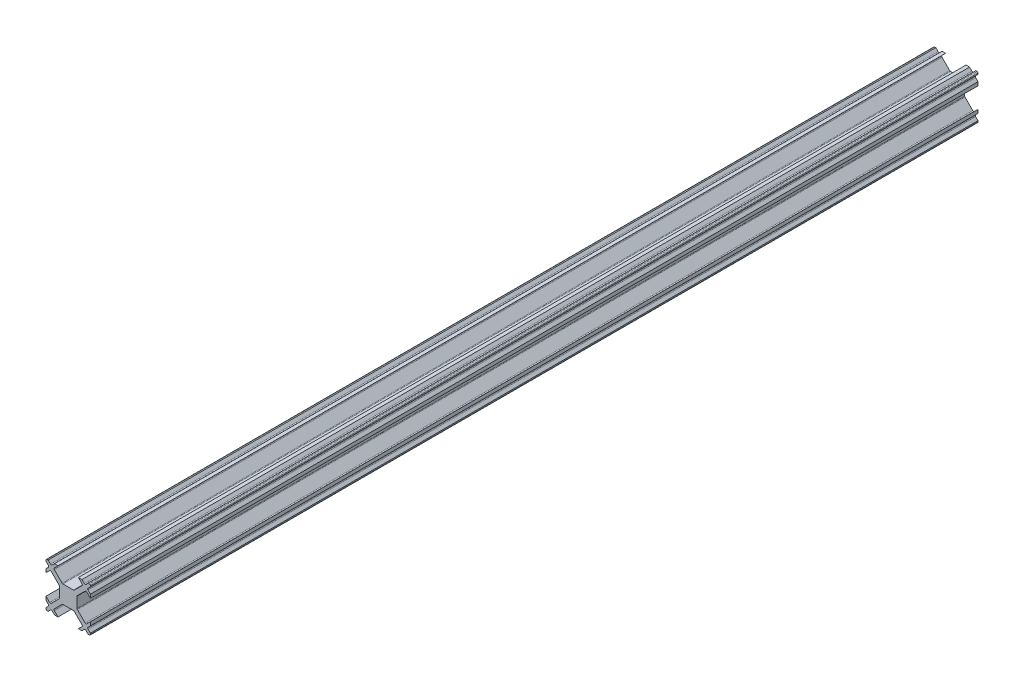
from build123d import *

# Parameters (mm, degrees)
BOSS_EXTRUDE1_DEPTH = 200


with BuildPart() as part:
    # Sketch1 → Boss-Extrude1 (new body)
    with BuildSketch(Plane.XY.offset(12.5)):
        with BuildLine():
            Line((1.189339828, 2), (-1.189339828, 2))
            ThreePointArc((-1.189339828, 2), (-1.285010686, 2.019030117), (-1.366116524, 2.073223305))
            Line((-1.366116524, 2.073223305), (-3.116116524, 3.823223305))
            ThreePointArc((-3.116116524, 3.823223305), (-3.189339828, 4), (-3.116116524, 4.176776695))
            Line((-3.116116524, 4.176776695), (-2.292893219, 5))
            Line((-2.292893219, 5), (-3.094974747, 5))
            Line((-3.094974747, 5), (-3.623223305, 4.471751442))
            ThreePointArc((-3.623223305, 4.471751442), (-3.8, 4.398528137), (-3.976776695, 4.471751442))
            Line((-3.976776695, 4.471751442), (-4.505025253, 5))
            Line((-4.505025253, 5), (-4.75, 5))
            ThreePointArc((-4.75, 5), (-4.926776695, 4.926776695), (-5, 4.75))
            Line((-5, 4.75), (-5, 4.505025253))
            Line((-5, 4.505025253), (-4.471751442, 3.976776695))
            ThreePointArc((-4.471751442, 3.976776695), (-4.398528137, 3.8), (-4.471751442, 3.623223305))
            Line((-4.471751442, 3.623223305), (-5, 3.094974747))
            Line((-5, 3.094974747), (-5, 2.292893219))
            Line((-5, 2.292893219), (-4.176776695, 3.116116524))
            ThreePointArc((-4.176776695, 3.116116524), (-4, 3.189339828), (-3.823223305, 3.116116524))
            Line((-3.823223305, 3.116116524), (-2.073223305, 1.366116524))
            ThreePointArc((-2.073223305, 1.366116524), (-2.019030117, 1.285010686), (-2, 1.189339828))
            Line((-2, 1.189339828), (-2, -1.189339828))
            ThreePointArc((-2, -1.189339828), (-2.019030117, -1.285010686), (-2.073223305, -1.366116524))
            Line((-2.073223305, -1.366116524), (-3.823223305, -3.116116524))
            ThreePointArc((-3.823223305, -3.116116524), (-4, -3.189339828), (-4.176776695, -3.116116524))
            Line((-4.176776695, -3.116116524), (-5, -2.292893219))
            Line((-5, -2.292893219), (-5, -3.094974747))
            Line((-5, -3.094974747), (-4.471751442, -3.623223305))
            ThreePointArc((-4.471751442, -3.623223305), (-4.398528137, -3.8), (-4.471751442, -3.976776695))
            Line((-4.471751442, -3.976776695), (-5, -4.505025253))
            Line((-5, -4.505025253), (-5, -4.75))
            ThreePointArc((-5, -4.75), (-4.926776695, -4.926776695), (-4.75, -5))
            Line((-4.75, -5), (-4.505025253, -5))
            Line((-4.505025253, -5), (-3.976776695, -4.471751442))
            ThreePointArc((-3.976776695, -4.471751442), (-3.8, -4.398528137), (-3.623223305, -4.471751442))
            Line((-3.623223305, -4.471751442), (-3.094974747, -5))
            Line((-3.094974747, -5), (-2.292893219, -5))
            Line((-2.292893219, -5), (-3.116116524, -4.176776695))
            ThreePointArc((-3.116116524, -4.176776695), (-3.189339828, -4), (-3.116116524, -3.823223305))
            Line((-3.116116524, -3.823223305), (-1.366116524, -2.073223305))
            ThreePointArc((-1.366116524, -2.073223305), (-1.285010686, -2.019030117), (-1.189339828, -2))
            Line((-1.189339828, -2), (1.189339828, -2))
            ThreePointArc((1.189339828, -2), (1.285010686, -2.019030117), (1.366116524, -2.073223305))
            Line((1.366116524, -2.073223305), (3.116116524, -3.823223305))
            ThreePointArc((3.116116524, -3.823223305), (3.189339828, -4), (3.116116524, -4.176776695))
            Line((3.116116524, -4.176776695), (2.292893219, -5))
            Line((2.292893219, -5), (3.094974747, -5))
            Line((3.094974747, -5), (3.623223305, -4.471751442))
            ThreePointArc((3.623223305, -4.471751442), (3.8, -4.398528137), (3.976776695, -4.471751442))
            Line((3.976776695, -4.471751442), (4.505025253, -5))
            Line((4.505025253, -5), (4.75, -5))
            ThreePointArc((4.75, -5), (4.926776695, -4.926776695), (5, -4.75))
            Line((5, -4.75), (5, -4.505025253))
            Line((5, -4.505025253), (4.471751442, -3.976776695))
            ThreePointArc((4.471751442, -3.976776695), (4.398528137, -3.8), (4.471751442, -3.623223305))
            Line((4.471751442, -3.623223305), (5, -3.094974747))
            Line((5, -3.094974747), (5, -2.292893219))
            Line((5, -2.292893219), (4.176776695, -3.116116524))
            ThreePointArc((4.176776695, -3.116116524), (4, -3.189339828), (3.823223305, -3.116116524))
            Line((3.823223305, -3.116116524), (2.073223305, -1.366116524))
            ThreePointArc((2.073223305, -1.366116524), (2.019030117, -1.285010686), (2, -1.189339828))
            Line((2, -1.189339828), (2, 1.189339828))
            ThreePointArc((2, 1.189339828), (2.019030117, 1.285010686), (2.073223305, 1.366116524))
            Line((2.073223305, 1.366116524), (3.823223305, 3.116116524))
            ThreePointArc((3.823223305, 3.116116524), (4, 3.189339828), (4.176776695, 3.116116524))
            Line((4.176776695, 3.116116524), (5, 2.292893219))
            Line((5, 2.292893219), (5, 3.094974747))
            Line((5, 3.094974747), (4.471751442, 3.623223305))
            ThreePointArc((4.471751442, 3.623223305), (4.398528137, 3.8), (4.471751442, 3.976776695))
            Line((4.471751442, 3.976776695), (5, 4.505025253))
            Line((5, 4.505025253), (5, 4.75))
            ThreePointArc((5, 4.75), (4.926776695, 4.926776695), (4.75, 5))
            Line((4.75, 5), (4.505025253, 5))
            Line((4.505025253, 5), (3.976776695, 4.471751442))
            ThreePointArc((3.976776695, 4.471751442), (3.8, 4.398528137), (3.623223305, 4.471751442))
            Line((3.623223305, 4.471751442), (3.094974747, 5))
            Line((3.094974747, 5), (2.292893219, 5))
            Line((2.292893219, 5), (3.116116524, 4.176776695))
            ThreePointArc((3.116116524, 4.176776695), (3.189339828, 4), (3.116116524, 3.823223305))
            Line((3.116116524, 3.823223305), (1.366116524, 2.073223305))
            ThreePointArc((1.366116524, 2.073223305), (1.285010686, 2.019030117), (1.189339828, 2))
        make_face()
    extrude(amount=-BOSS_EXTRUDE1_DEPTH)


solid = part.part
